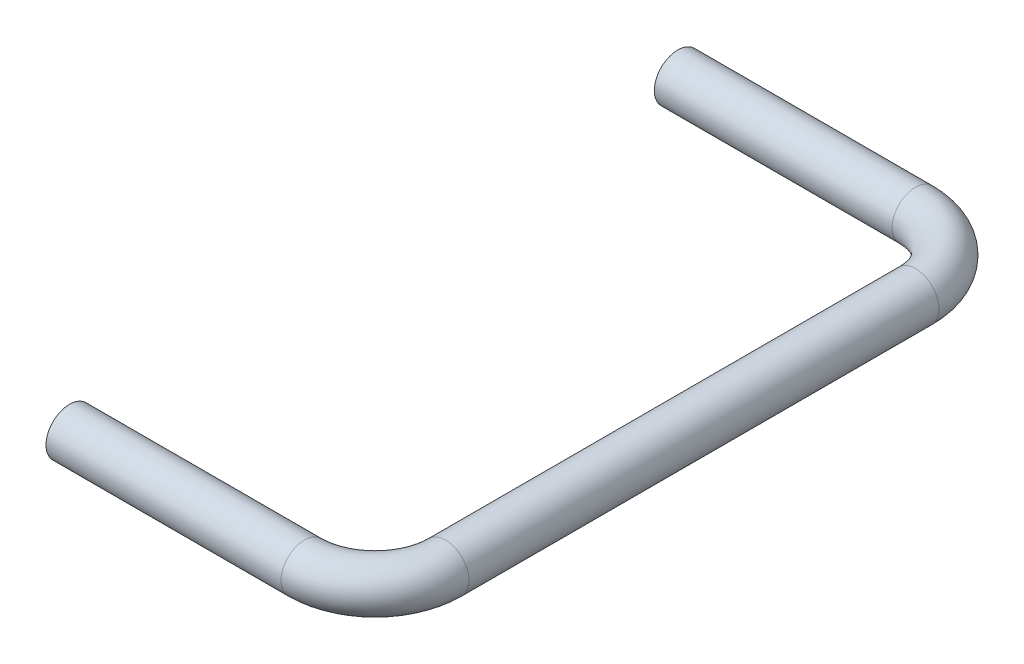
from build123d import *

# Parameters (mm, degrees)
SKETCH_1_R = 1


with BuildPart() as part:
    # По траектории1: sweep along a curve in space
    with BuildLine() as sweep_1_path:
        Line((0, 0, 0), (10, 0, 0))
        ThreePointArc((10, 0, 0), (12.121320344, 0, -0.878679656), (13, 0, -3))
        Line((13, 0, -3), (13, 0, -23))
        ThreePointArc((13, 0, -23), (12.121320344, 0, -25.121320344), (10, 0, -26))
        Line((10, 0, -26), (-0.116555464, 0, -26))
    # Эскиз1 → По траектории1 (sweep)
    with BuildSketch(Plane(origin=(0, 0, 0), x_dir=(0, 0, -1), z_dir=(1, 0, 0))):
        Circle(SKETCH_1_R)
    sweep(path=sweep_1_path.line)


solid = part.part
